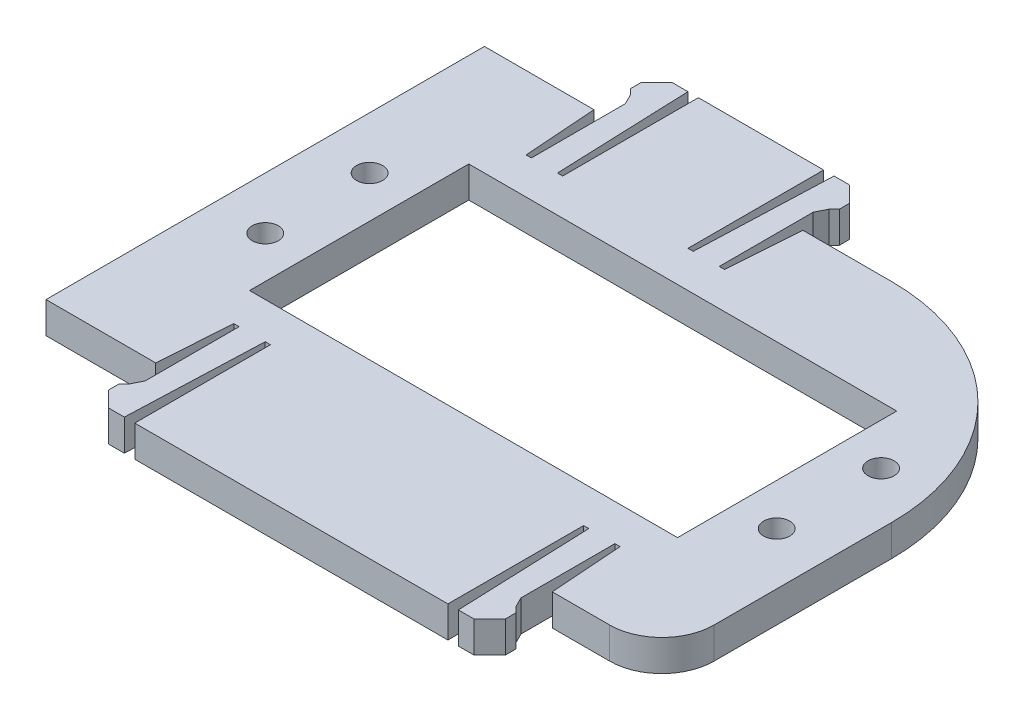
from build123d import *

# Parameters (mm, degrees)
BOSS_EXTRUDE4_DEPTH = 3
SKETCH7_R           = 1.25
SKETCH7_W           = 41
SKETCH7_H           = 21
CUT_EXTRUDE1_DEPTH  = 3
FILLET2_R           = 20
FILLET3_R           = 5


with BuildPart() as part:
    # Sketch1 → Boss-Extrude4 (new body)
    with BuildSketch(Plane(origin=(0, 0, 0), x_dir=(1, 0, 0), z_dir=(0, 1, 0))):
        Polygon((19, -21), (29.5, -21), (29.5, 21), (1, 21), (0.5, 13.997828908), (0, 13.997828908), (0, 22.997828908), (0.5, 23.997828908), (1, 24.497828908), (1, 25.497828908), (-0.5, 26.997828908), (-2, 26.997828908), (-2.5, 13.997828908), (-3, 13.997828908), (-3, 26.997828908), (-15, 26.997828908), (-15, 13.997828908), (-15.5, 13.997828908), (-16, 26.997828908), (-17.5, 26.997828908), (-19, 25.497828908), (-19, 24.497828908), (-18.5, 23.997828908), (-18, 22.997828908), (-18, 13.997828908), (-18.5, 13.997828908), (-19, 21), (-29.5, 21), (-29.5, -21), (-19, -21), (-18.5, -13.997828908), (-18, -13.997828908), (-18, -22.997828908), (-18.5, -23.997828908), (-19, -24.497828908), (-19, -25.497828908), (-17.5, -26.997828908), (-16, -26.997828908), (-15.5, -13.997828908), (-15, -13.997828908), (-15, -26.997828908), (15, -26.997828908), (15, -13.997828908), (15.5, -13.997828908), (16, -26.997828908), (17.5, -26.997828908), (19, -25.497828908), (19, -24.497828908), (18.5, -23.997828908), (18, -22.997828908), (18, -13.997828908), (18.5, -13.997828908), align=None)
    extrude(amount=BOSS_EXTRUDE4_DEPTH)

    # Sketch7 → Cut-Extrude1 (cut)
    with BuildSketch(Plane(origin=(0, 3, 0), x_dir=(1, 0, 0), z_dir=(0, 1, 0))):
        with Locations((-24.5, 5)):
            Circle(SKETCH7_R)
        with Locations((-24.5, -5)):
            Circle(SKETCH7_R)
        with Locations((24.5, -5)):
            Circle(SKETCH7_R)
        with Locations((24.5, 5)):
            Circle(SKETCH7_R)
        Rectangle(SKETCH7_W, SKETCH7_H)
    extrude(amount=-CUT_EXTRUDE1_DEPTH, mode=Mode.SUBTRACT)

    # Fillet2
    fillet2_edges = [part.edges().sort_by_distance(p)[0] for p in [
        (29.5, 1.5, -21),
    ]]
    fillet(fillet2_edges, radius=FILLET2_R)

    # Fillet3
    fillet3_edges = [part.edges().sort_by_distance(p)[0] for p in [
        (29.5, 1.5, 21),
    ]]
    fillet(fillet3_edges, radius=FILLET3_R)


solid = part.part
